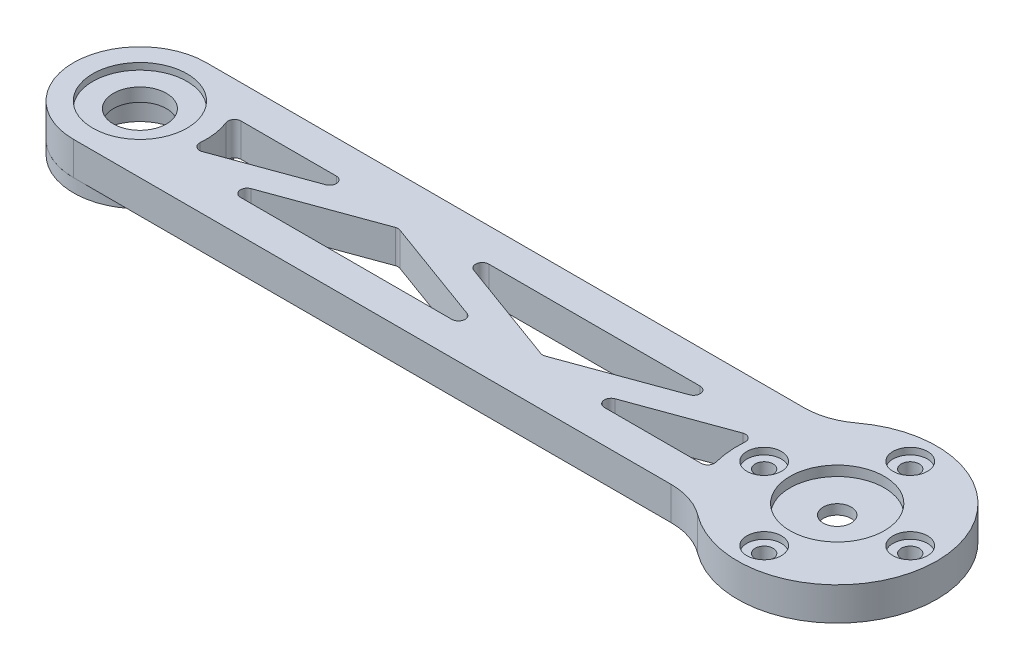
from build123d import *

# Parameters (mm, degrees)
SKETCH_1_R          = 1.35
SKETCH_1_R_2        = 7.1
EXTRUDE_1_DEPTH     = 5
EXTRUDE_START       = 1.5
SKETCH_1_4_R        = 6.1
SKETCH_1_4_R_2      = 2.1
EXTRUDE_3_DEPTH     = 2
FILLET_1_R          = 1
FILLET_2_R          = 1
FILLET_3_R          = 1
FILLET_4_R          = 1
FILLET_5_R          = 10
SKETCH_1_9_R        = 7.1
SKETCH_1_9_R_2      = 6.1
EXTRUDE_4_DEPTH     = 4
EXTRUDE_START_2     = 2
SKETCH_1_10_R       = 6.1
SKETCH_1_10_R_2     = 4
EXTRUDE_5_DEPTH     = 2
SKETCH_2_R          = 10
SKETCH_2_R_2        = 6.1
EXTRUDE_6_DEPTH     = 2
SKETCH_1_11_R       = 7.1
SKETCH_1_11_R_2     = 6.1
EXTRUDE_7_DEPTH     = 3.5
CUT_EXTRUDE_START   = 4
SKETCH_1_15_R       = 2.6
SKETCH_1_15_R_2     = 1.35
CUT_EXTRUDE_1_DEPTH = 1
SKETCH_3_R          = 3.1
SKETCH_3_R_2        = 2.1
CUT_EXTRUDE_2_DEPTH = 0.5


with BuildPart() as part:
    # Sketch 1 → Extrude 1 (new body)
    with BuildSketch(Plane(origin=(0, 0, 0), x_dir=(1, 0, 0), z_dir=(0, 1, 0))):
        with BuildLine():
            Line((-105, 10), (-11.180339887, 10))
            ThreePointArc((-11.180339887, 10), (15, 0), (-11.180339887, -10))
            Line((-11.180339887, -10), (-105, -10))
            ThreePointArc((-105, -10), (-115, 0), (-105, 10))
        make_face()
        with Locations(Location((-11, 0, 0), (0, 0, 270))):
            Circle(SKETCH_1_R, mode=Mode.SUBTRACT)
        with Locations(Location((0, 11, 0), (0, 0, 270))):
            Circle(SKETCH_1_R, mode=Mode.SUBTRACT)
        with Locations(Location((11, 0, 0), (0, 0, 270))):
            Circle(SKETCH_1_R, mode=Mode.SUBTRACT)
        with Locations(Location((0, -11, 0), (0, 0, 270))):
            Circle(SKETCH_1_R, mode=Mode.SUBTRACT)
        with Locations(Location((-105, 0, 0), (0, 0, 270))):
            Circle(SKETCH_1_R_2, mode=Mode.SUBTRACT)
        with Locations(Location((0, 0, 0), (0, 0, 270))):
            Circle(SKETCH_1_R_2, mode=Mode.SUBTRACT)
        Polygon((-90.506337526, -5), (-47.374747506, -5), (-68.940542516, 2.870956925), align=None, mode=Mode.SUBTRACT)
        with BuildLine():
            Line((-96.339745962, 5), (-74.773950952, 5))
            Line((-74.773950952, 5), (-95.316937296, -2.497658238))
            ThreePointArc((-95.316937296, -2.497658238), (-95.091769228, 1.351651939), (-96.339745962, 5))
        make_face(mode=Mode.SUBTRACT)
        Polygon((-63.10713408, 5), (-41.54133907, -2.870956925), (-19.97554406, 5), align=None, mode=Mode.SUBTRACT)
        with BuildLine():
            Line((-35.707930634, -5), (-14.76521769, 2.6435481))
            ThreePointArc((-14.76521769, 2.6435481), (-14.950408884, -1.218718263), (-14.142135624, -5))
            Line((-14.142135624, -5), (-35.707930634, -5))
        make_face(mode=Mode.SUBTRACT)
    extrude(amount=EXTRUDE_1_DEPTH)

    # Fillet 1
    fillet_1_edges = [part.edges().sort_by_distance(p)[0] for p in [
        (-74.773950952, 2.5, -5),
        (-96.339745962, 2.5, -5),
        (-95.316937296, 2.5, 2.497658238),
    ]]
    fillet(fillet_1_edges, radius=FILLET_1_R)

    # Fillet 2
    fillet_2_edges = [part.edges().sort_by_distance(p)[0] for p in [
        (-90.506337526, 2.5, 5),
        (-47.374747506, 2.5, 5),
        (-68.940542516, 2.5, -2.870956925),
    ]]
    fillet(fillet_2_edges, radius=FILLET_2_R)

    # Fillet 3
    fillet_3_edges = [part.edges().sort_by_distance(p)[0] for p in [
        (-41.54133907, 2.5, 2.870956925),
        (-19.97554406, 2.5, -5),
        (-63.10713408, 2.5, -5),
    ]]
    fillet(fillet_3_edges, radius=FILLET_3_R)

    # Fillet 4
    fillet_4_edges = [part.edges().sort_by_distance(p)[0] for p in [
        (-35.707930634, 2.5, 5),
        (-14.142135624, 2.5, 5),
        (-14.76521769, 2.5, -2.6435481),
    ]]
    fillet(fillet_4_edges, radius=FILLET_4_R)

    # Fillet 5
    fillet_5_edges = [part.edges().sort_by_distance(p)[0] for p in [
        (-11.180339887, 2.5, -10),
        (-11.180339887, 2.5, 10),
    ]]
    fillet(fillet_5_edges, radius=FILLET_5_R)



with BuildPart() as body_2:
    # Sketch 1_4 → Extrude 3 (new body)
    with BuildSketch(Plane(origin=(0, 0, 0), x_dir=(1, 0, 0), z_dir=(0, 1, 0)).offset(EXTRUDE_START)):
        with Locations(Location((0, 0, 0), (0, 0, 270))):
            Circle(SKETCH_1_4_R)
        with Locations(Location((0, 0, 0), (0, 0, 270))):
            Circle(SKETCH_1_4_R_2, mode=Mode.SUBTRACT)
    extrude(amount=EXTRUDE_3_DEPTH)


with BuildPart() as body_3:
    # Sketch 1_9 → Extrude 4 (new body)
    with BuildSketch(Plane(origin=(0, 0, 0), x_dir=(1, 0, 0), z_dir=(0, 1, 0))):
        with Locations(Location((-105, 0, 0), (0, 0, 270))):
            Circle(SKETCH_1_9_R)
        with Locations(Location((-105, 0, 0), (0, 0, 270))):
            Circle(SKETCH_1_9_R_2, mode=Mode.SUBTRACT)
    extrude(amount=EXTRUDE_4_DEPTH)

    # Sketch 1_10 → Extrude 5 (add)
    with BuildSketch(Plane(origin=(0, 0, 0), x_dir=(1, 0, 0), z_dir=(0, 1, 0)).offset(EXTRUDE_START_2)):
        with Locations(Location((-105, 0, 0), (0, 0, 270))):
            Circle(SKETCH_1_10_R)
        with Locations(Location((-105, 0, 0), (0, 0, 270))):
            Circle(SKETCH_1_10_R_2, mode=Mode.SUBTRACT)
    extrude(amount=EXTRUDE_5_DEPTH)

    # Sketch 2 → Extrude 6 (add)
    with BuildSketch(Plane.XZ.offset(EXTRUDE_START_2)):
        with Locations(Location((-105, 0, 0), (0, 0, 270))):
            Circle(SKETCH_2_R)
        with Locations(Location((-105, 0, 0), (0, 0, 270))):
            Circle(SKETCH_2_R_2, mode=Mode.SUBTRACT)
    extrude(amount=-EXTRUDE_6_DEPTH)


with BuildPart() as part_1:
    add(part.part)

    add(body_2.part)  # Extrude 7 merges body 2
    # Sketch 1_11 → Extrude 7 (add)
    with BuildSketch(Plane(origin=(0, 0, 0), x_dir=(1, 0, 0), z_dir=(0, 1, 0))):
        with Locations(Location((0, 0, 0), (0, 0, 270))):
            Circle(SKETCH_1_11_R)
        with Locations(Location((0, 0, 0), (0, 0, 270))):
            Circle(SKETCH_1_11_R_2, mode=Mode.SUBTRACT)
    extrude(amount=EXTRUDE_7_DEPTH)

    # Sketch 1_15 → Cut-Extrude 1 (cut)
    # profile 1 of 4: a face of its own
    with BuildSketch(Plane(origin=(0, 0, 0), x_dir=(1, 0, 0), z_dir=(0, 1, 0)).offset(CUT_EXTRUDE_START)):
        with Locations((-11, 0)):
            Circle(SKETCH_1_15_R)
        with Locations((-11, 0)):
            Circle(SKETCH_1_15_R_2, mode=Mode.SUBTRACT)
    # profile 2 of 4: a face of its own
    with BuildSketch(Plane(origin=(0, 0, 0), x_dir=(1, 0, 0), z_dir=(0, 1, 0)).offset(CUT_EXTRUDE_START)):
        with Locations((0, 11)):
            Circle(SKETCH_1_15_R)
        with Locations((0, 11)):
            Circle(SKETCH_1_15_R_2, mode=Mode.SUBTRACT)
    # profile 3 of 4: a face of its own
    with BuildSketch(Plane(origin=(0, 0, 0), x_dir=(1, 0, 0), z_dir=(0, 1, 0)).offset(CUT_EXTRUDE_START)):
        with Locations((11, 0)):
            Circle(SKETCH_1_15_R)
        with Locations((11, 0)):
            Circle(SKETCH_1_15_R_2, mode=Mode.SUBTRACT)
    # profile 4 of 4: a face of its own
    with BuildSketch(Plane(origin=(0, 0, 0), x_dir=(1, 0, 0), z_dir=(0, 1, 0)).offset(CUT_EXTRUDE_START)):
        with Locations((0, -11)):
            Circle(SKETCH_1_15_R)
        with Locations((0, -11)):
            Circle(SKETCH_1_15_R_2, mode=Mode.SUBTRACT)
    extrude(amount=CUT_EXTRUDE_1_DEPTH, mode=Mode.SUBTRACT)

    # Sketch 3 → Cut-Extrude 2 (cut)
    with BuildSketch(Plane.XZ.offset(-1.5)):
        Circle(SKETCH_3_R)
        Circle(SKETCH_3_R_2, mode=Mode.SUBTRACT)
    extrude(amount=-CUT_EXTRUDE_2_DEPTH, mode=Mode.SUBTRACT)


solid = Compound([body_3.part, part_1.part])
